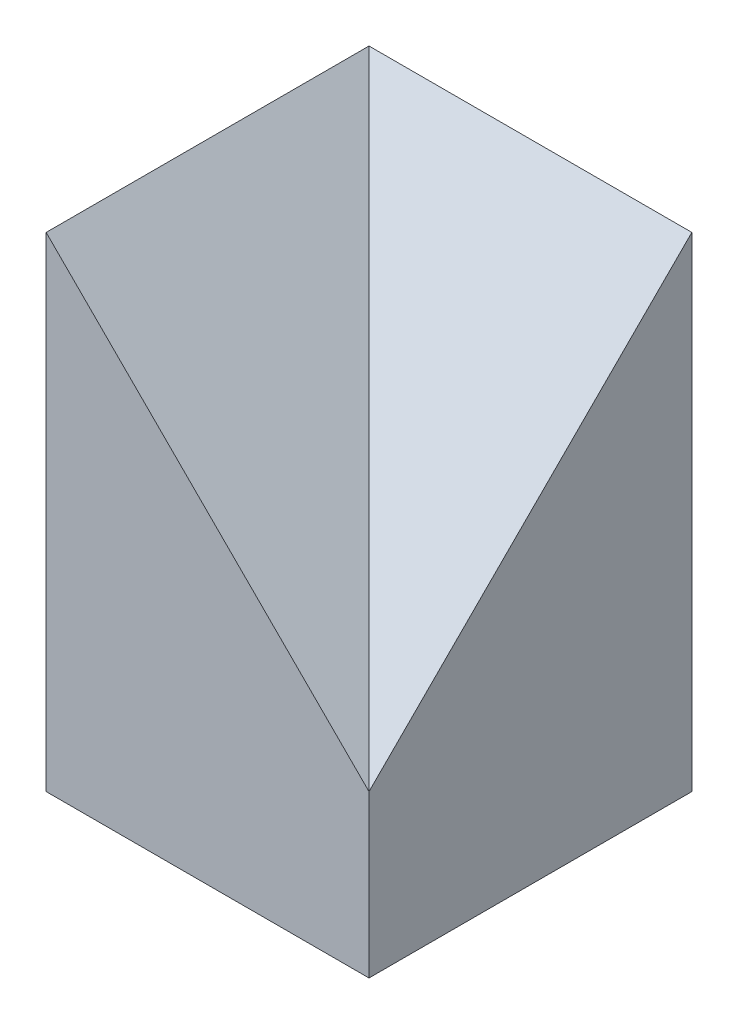
from build123d import *

# Parameters (mm, degrees)
SKIZZE1_W                       = 400
SKIZZE1_H                       = 400
AUFSATZ_LINEAR_AUSTRAGEN1_DEPTH = 200
SKIZZE2_W                       = 400
SKIZZE2_H                       = 400
AUFSATZ_LINEAR_AUSTRAGEN2_DEPTH = 400
SKIZZE3_W                       = 400
SKIZZE3_H                       = 400


with BuildPart() as part:
    # Skizze1 → Aufsatz-Linear austragen1 (new body)
    with BuildSketch(Plane(origin=(0, 0, 0), x_dir=(1, 0, 0), z_dir=(0, 1, 0))):
        with Locations((200, -200)):
            Rectangle(SKIZZE1_W, SKIZZE1_H)
    extrude(amount=AUFSATZ_LINEAR_AUSTRAGEN1_DEPTH)

    # Skizze2 → Aufsatz-Linear austragen2 (add)
    with BuildSketch(Plane(origin=(0, 200, 0), x_dir=(1, 0, 0), z_dir=(0, 1, 0))):
        with Locations((200, -200)):
            Rectangle(SKIZZE2_W, SKIZZE2_H)
    extrude(amount=AUFSATZ_LINEAR_AUSTRAGEN2_DEPTH)

    # Skizze3 → Schnitt-Ausformung1 section 0
    with BuildSketch(Plane(origin=(0, 600, 0), x_dir=(1, 0, 0), z_dir=(0, 1, 0)), mode=Mode.PRIVATE) as schnitt_ausformung1_s0:
        with Locations((200, -200)):
            Rectangle(SKIZZE3_W, SKIZZE3_H)
    loft([schnitt_ausformung1_s0.sketch, Vertex(400, 200, 400)], mode=Mode.SUBTRACT)


solid = part.part
